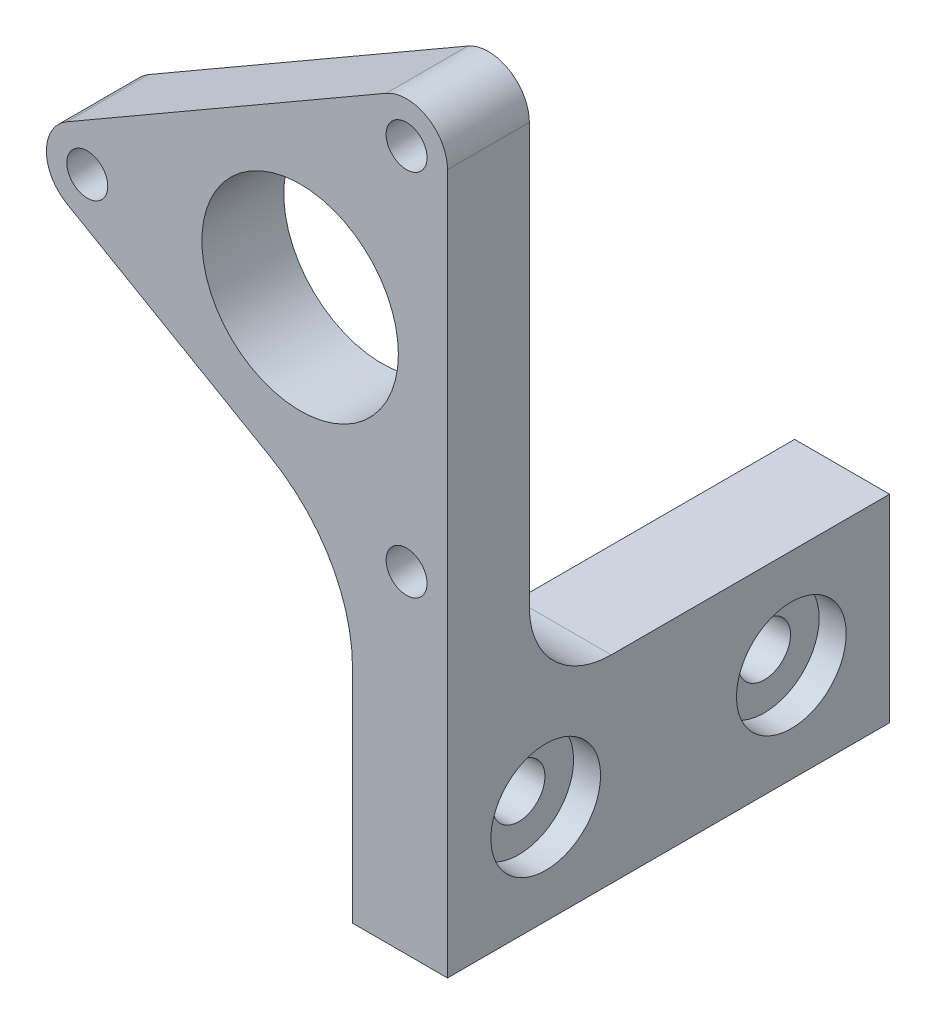
from build123d import *

# Parameters (mm, degrees)
ESBO_O1_R                          = 6
ESBO_O1_R_2                        = 1.25
RESSALTO_EXTRUS_O1_DEPTH           = 5
ESBO_O2_W                          = 5.8
ESBO_O2_H                          = 12.09
RESSALTO_EXTRUS_O2_DEPTH           = 22
REBAIXO_PARA_SBHCS_M31_D           = 3.2
REBAIXO_PARA_SBHCS_M31_DEPTH       = 5.8
REBAIXO_PARA_SBHCS_M31_CBORE_D     = 6.7
REBAIXO_PARA_SBHCS_M31_CBORE_DEPTH = 1.65
FILETE1_R                          = 5


with BuildPart() as part:
    # Esboço1 → Ressalto-extrusão1 (new body)
    with BuildSketch(Plane.XY):
        with BuildLine():
            Line((-14.25, 2.165063509), (5.25, 13.423393759))
            ThreePointArc((5.25, 13.423393759), (7.75, 13.423393759), (9, 11.258330249))
            Line((9, 11.258330249), (9, -11.258330249))
            Line((9, -11.258330249), (9, -31.498330249))
            Line((9, -31.498330249), (3.2, -31.498330249))
            Line((3.2, -31.498330249), (3.2, -19.408330249))
            Line((3.2, -19.408330249), (3.2, -18.013328399))
            ThreePointArc((3.2, -18.013328399), (1.860254038, -13.013328399), (-1.8, -9.353074361))
            Line((-1.8, -9.353074361), (-14.25, -2.165063509))
            ThreePointArc((-14.25, -2.165063509), (-15.5, 0), (-14.25, 2.165063509))
        make_face()
        Circle(ESBO_O1_R, mode=Mode.SUBTRACT)
        with Locations((6.5, -11.258330249)):
            Circle(ESBO_O1_R_2, mode=Mode.SUBTRACT)
        with Locations((6.5, 11.258330249)):
            Circle(ESBO_O1_R_2, mode=Mode.SUBTRACT)
        with Locations((-13, 0)):
            Circle(ESBO_O1_R_2, mode=Mode.SUBTRACT)
    extrude(amount=RESSALTO_EXTRUS_O1_DEPTH)

    # Esboço2 → Ressalto-extrusão2 (add)
    with BuildSketch(Plane(origin=(0, 0, 0), x_dir=(-1, 0, 0), z_dir=(0, 0, -1))):
        with Locations((-6.1, -25.453330249)):
            Rectangle(ESBO_O2_W, ESBO_O2_H)
    extrude(amount=RESSALTO_EXTRUS_O2_DEPTH)

    # Rebaixo para SBHCS M31
    with Locations(Plane(origin=(9, 0, 0), x_dir=(0, 0, -1), z_dir=(1, 0, 0))):
        with Locations((1, -25.453330249), (16, -25.453330249)):
            CounterBoreHole(REBAIXO_PARA_SBHCS_M31_D / 2, REBAIXO_PARA_SBHCS_M31_CBORE_D / 2, REBAIXO_PARA_SBHCS_M31_CBORE_DEPTH, depth=REBAIXO_PARA_SBHCS_M31_DEPTH)

    # Filete1
    filete1_edges = [part.edges().sort_by_distance(p)[0] for p in [
        (6.1, -19.408330249, 0),
    ]]
    fillet(filete1_edges, radius=FILETE1_R)


solid = part.part
